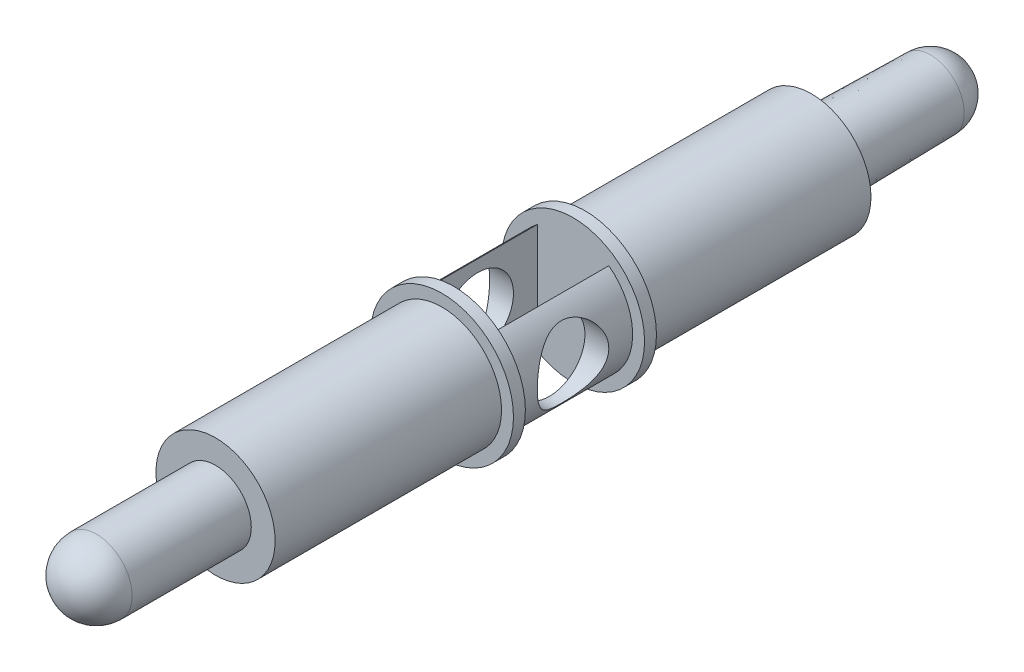
from build123d import *

# Parameters (mm, degrees)
SKETCH2_R               = 5
BOSS_EXTRUDE1_DEPTH     = 50
SKETCH3_R               = 3
BOSS_EXTRUDE2_DEPTH     = 10
BOSS_EXTRUDE2_TAPER     = 1
SKETCH5_R               = 3
BOSS_EXTRUDE3_DEPTH     = 10
CUT_EXTRUDE1_DEPTH      = 10
CUT_EXTRUDE1_DEPTH_BACK = 10
SKETCH7_W               = 6
SKETCH7_H               = 10
CUT_EXTRUDE2_DEPTH      = 10
CUT_EXTRUDE2_DEPTH_BACK = 10
SKETCH8_R               = 3
SKETCH10_R              = 6
BOSS_EXTRUDE4_DEPTH     = 1
BOSS_EXTRUDE5_START     = 1
SKETCH11_R              = 6
BOSS_EXTRUDE5_DEPTH     = 1


with BuildPart() as part:
    # Sketch2 → Boss-Extrude1 (new body)
    with BuildSketch(Plane.XY):
        Circle(SKETCH2_R)
    extrude(amount=BOSS_EXTRUDE1_DEPTH)

    # Sketch3 → Boss-Extrude2 (add)
    with BuildSketch(Plane(origin=(0, 0, 0), x_dir=(-1, 0, 0), z_dir=(0, 0, -1))):
        Circle(SKETCH3_R)
    extrude(amount=BOSS_EXTRUDE2_DEPTH, taper=BOSS_EXTRUDE2_TAPER)

    # Sketch5 → Boss-Extrude3 (add)
    with BuildSketch(Plane.XY.offset(50)):
        Circle(SKETCH5_R)
    extrude(amount=BOSS_EXTRUDE3_DEPTH)

    # Sketch7 → Cut-Extrude1 (cut, two sides: drawn at the far end of the back side and taken through both)
    with BuildSketch(Plane(origin=(0, 0, 0), x_dir=(1, 0, 0), z_dir=(0, 1, 0)).offset(-CUT_EXTRUDE1_DEPTH_BACK)):
        with Locations((0, -25)):
            Rectangle(SKETCH7_W, SKETCH7_H)
    extrude(amount=CUT_EXTRUDE1_DEPTH + CUT_EXTRUDE1_DEPTH_BACK, mode=Mode.SUBTRACT)

    # Sketch8 → Cut-Extrude2 (cut, two sides: drawn at the far end of the back side and taken through both)
    with BuildSketch(Plane(origin=(0, 0, 0), x_dir=(0, 0, -1), z_dir=(1, 0, 0)).offset(-CUT_EXTRUDE2_DEPTH_BACK)):
        with Locations((-25, 0)):
            Circle(SKETCH8_R)
    extrude(amount=CUT_EXTRUDE2_DEPTH + CUT_EXTRUDE2_DEPTH_BACK, mode=Mode.SUBTRACT)

    # Sketch6 → Revolve1 (revolve)
    with BuildSketch(Plane.XY.offset(60)):
        with BuildLine():
            Line((0, 3), (0, -3))
            ThreePointArc((0, -3), (-3, 0), (0, 3))
        make_face()
    revolve(axis=Axis((0, 3, 60), (0, -1, 0)))

    # Sketch4 → Revolve2 (revolve)
    with BuildSketch(Plane(origin=(0, 0, -10), x_dir=(-1, 0, 0), z_dir=(0, 0, -1))):
        with BuildLine():
            Line((0, 2.825449351), (0, -2.825449351))
            ThreePointArc((0, -2.825449351), (-2.825449351, 0), (0, 2.825449351))
        make_face()
    revolve(axis=Axis((0, 2.825449351, -10), (0, -1, 0)))

    # Sketch10 → Boss-Extrude4 (add)
    with BuildSketch(Plane.XY.offset(20)):
        Circle(SKETCH10_R)
    extrude(amount=-BOSS_EXTRUDE4_DEPTH)

    # Sketch11 → Boss-Extrude5 (add)
    with BuildSketch(Plane.XY.offset(30).offset(BOSS_EXTRUDE5_START)):
        Circle(SKETCH11_R)
    extrude(amount=-BOSS_EXTRUDE5_DEPTH)


solid = part.part
